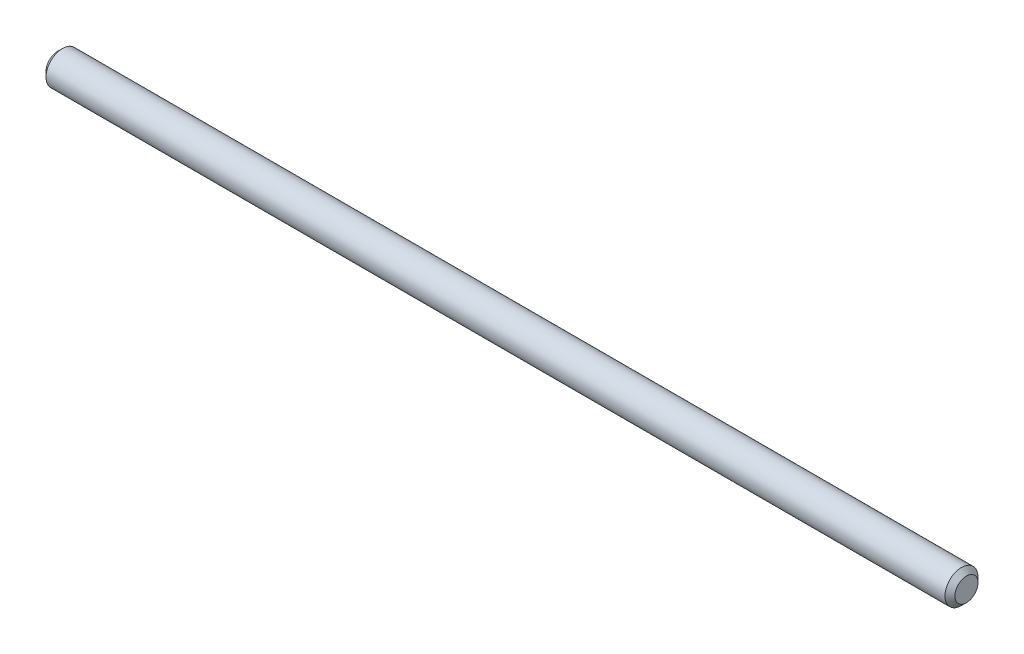
from build123d import *

# Parameters (mm, degrees)
SKETCH2_R                = 3.175
BOSS_EXTRUDE1_DEPTH      = 87.3125
BOSS_EXTRUDE1_DEPTH_BACK = 87.3125
CHAMFER1_SIZE            = 0.9525


with BuildPart() as part:
    # Sketch2 → Boss-Extrude1 (new body, two sides)
    with BuildSketch(Plane(origin=(0, 0, 0), x_dir=(0, 0, -1), z_dir=(1, 0, 0))) as boss_extrude1_sk:
        Circle(SKETCH2_R)
    extrude(amount=BOSS_EXTRUDE1_DEPTH)
    extrude(boss_extrude1_sk.sketch, amount=-BOSS_EXTRUDE1_DEPTH_BACK)

    # Chamfer1
    chamfer1_edges = [part.edges().sort_by_distance(p)[0] for p in [
        (-87.3125, 0, 3.175),
        (87.3125, 0, 3.175),
    ]]
    chamfer(chamfer1_edges, length=CHAMFER1_SIZE)


solid = part.part
